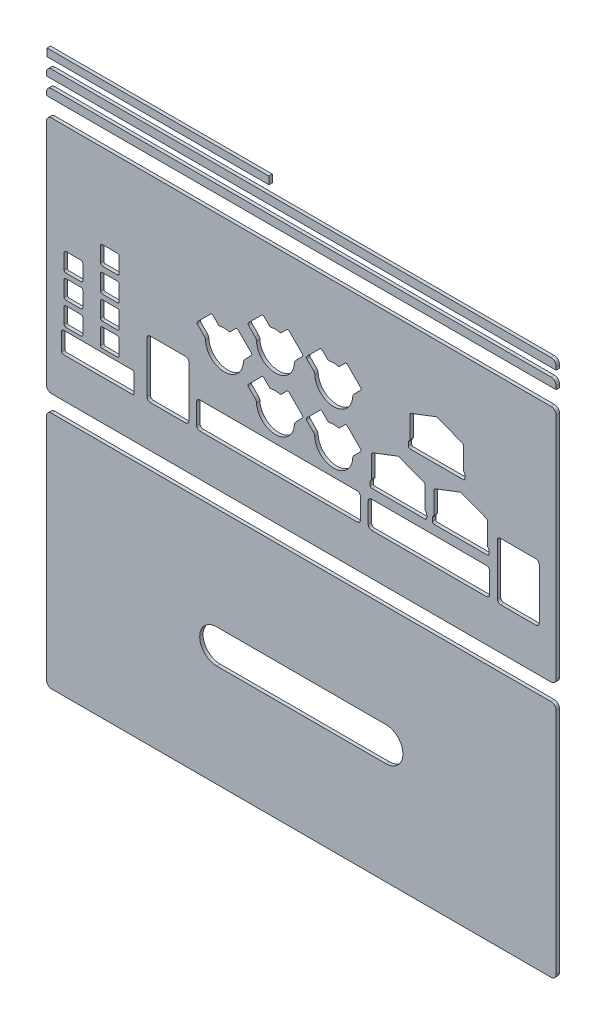
from build123d import *

# Parameters (mm, degrees)
SKETCH_1_W             = 301
SKETCH_1_H             = 141
SKETCH_1_W_2           = 11
SKETCH_1_H_2           = 11
SKETCH_1_W_3           = 42.882009629
SKETCH_1_H_3           = 12.463384351
EXTRUDE_1_DEPTH        = 2
FILLET_1_R             = 3
FILLET_2_R             = 1
SKETCH_2_W             = 301
SKETCH_2_H             = 5
EXTRUDE_2_DEPTH        = 2
FILLET_3_R             = 3
PATTERN_LINEAR_1_COUNT = 2
PATTERN_LINEAR_1_PITCH = 10
SKETCH_3_W             = 131
SKETCH_3_H             = 4.5
EXTRUDE_3_DEPTH        = 2
SKETCH_4_W             = 301
SKETCH_4_H             = 141
EXTRUDE_4_DEPTH        = 2
FILLET_4_R             = 3
CUT_EXTRUDE_1_DEPTH    = 2


with BuildPart() as part:
    # 草图1 → 凸台-拉伸1 (new body)
    with BuildSketch(Plane.XY):
        with Locations((145.5, 65.5)):
            Rectangle(SKETCH_1_W, SKETCH_1_H)
        with BuildLine():
            Line((107.479342602, 83.3954791), (103.152633216, 79.068769714))
            ThreePointArc((103.152633216, 79.068769714), (100.048889892, 79.525854826), (96.945146567, 79.068769714))
            Line((96.945146567, 79.068769714), (92.630133634, 83.383782646))
            Line((92.630133634, 83.383782646), (83.501399592, 74.255048604))
            Line((83.501399592, 74.255048604), (88.051647854, 69.704800341))
            ThreePointArc((88.051647854, 69.704800341), (88.68925935, 68.747618373), (88.908844178, 67.618668312))
            ThreePointArc((88.908844178, 67.618668312), (100.084096134, 57.15569059), (111.270007089, 67.607272058))
            ThreePointArc((111.270007089, 67.607272058), (111.532715847, 68.742609725), (112.190132556, 69.704800341))
            Line((112.190132556, 69.704800341), (116.680076959, 74.194744744))
            Line((116.680076959, 74.194744744), (107.479342602, 83.3954791))
        make_face(mode=Mode.SUBTRACT)
        with BuildLine():
            Line((137.61695402, 97.935247029), (133.290244634, 93.608537643))
            ThreePointArc((133.290244634, 93.608537643), (130.186501309, 94.065622755), (127.082757985, 93.608537643))
            Line((127.082757985, 93.608537643), (122.767745052, 97.923550576))
            Line((122.767745052, 97.923550576), (113.639011009, 88.794816533))
            Line((113.639011009, 88.794816533), (118.189259272, 84.24456827))
            ThreePointArc((118.189259272, 84.24456827), (118.826870768, 83.287386303), (119.046455596, 82.158436241))
            ThreePointArc((119.046455596, 82.158436241), (130.221707552, 71.695458519), (141.407618507, 82.147039988))
            ThreePointArc((141.407618507, 82.147039988), (141.670327265, 83.282377655), (142.327743974, 84.24456827))
            Line((142.327743974, 84.24456827), (146.817688376, 88.734512673))
            Line((146.817688376, 88.734512673), (137.61695402, 97.935247029))
        make_face(mode=Mode.SUBTRACT)
        with BuildLine():
            Line((172.054755422, 97.935247029), (167.728046035, 93.608537643))
            ThreePointArc((167.728046035, 93.608537643), (164.624302711, 94.065622755), (161.520559387, 93.608537643))
            Line((161.520559387, 93.608537643), (157.205546454, 97.923550576))
            Line((157.205546454, 97.923550576), (148.076812411, 88.794816533))
            Line((148.076812411, 88.794816533), (152.627060674, 84.24456827))
            ThreePointArc((152.627060674, 84.24456827), (153.26467217, 83.287386303), (153.484256998, 82.158436241))
            ThreePointArc((153.484256998, 82.158436241), (164.659508954, 71.695458519), (175.845419909, 82.147039988))
            ThreePointArc((175.845419909, 82.147039988), (176.108128666, 83.282377655), (176.765545376, 84.24456827))
            Line((176.765545376, 84.24456827), (181.255489778, 88.734512673))
            Line((181.255489778, 88.734512673), (172.054755422, 97.935247029))
        make_face(mode=Mode.SUBTRACT)
        with BuildLine():
            Line((172.008536395, 66.461273637), (167.681827008, 62.13456425))
            ThreePointArc((167.681827008, 62.13456425), (164.578083684, 62.591649363), (161.474340359, 62.13456425))
            Line((161.474340359, 62.13456425), (157.159327427, 66.449577183))
            Line((157.159327427, 66.449577183), (148.030593384, 57.32084314))
            Line((148.030593384, 57.32084314), (152.580841647, 52.770594878))
            ThreePointArc((152.580841647, 52.770594878), (153.218453142, 51.81341291), (153.43803797, 50.684462848))
            ThreePointArc((153.43803797, 50.684462848), (164.613289926, 40.221485126), (175.799200881, 50.673066595))
            ThreePointArc((175.799200881, 50.673066595), (176.061909639, 51.808404262), (176.719326348, 52.770594878))
            Line((176.719326348, 52.770594878), (181.209270751, 57.26053928))
            Line((181.209270751, 57.26053928), (172.008536395, 66.461273637))
        make_face(mode=Mode.SUBTRACT)
        with BuildLine():
            Line((137.61695402, 66.461273637), (133.290244634, 62.13456425))
            ThreePointArc((133.290244634, 62.13456425), (130.186501309, 62.591649363), (127.082757985, 62.13456425))
            Line((127.082757985, 62.13456425), (122.767745052, 66.449577183))
            Line((122.767745052, 66.449577183), (113.639011009, 57.32084314))
            Line((113.639011009, 57.32084314), (118.189259272, 52.770594878))
            ThreePointArc((118.189259272, 52.770594878), (118.826870768, 51.81341291), (119.046455596, 50.684462848))
            ThreePointArc((119.046455596, 50.684462848), (130.221707552, 40.221485126), (141.407618507, 50.673066595))
            ThreePointArc((141.407618507, 50.673066595), (141.670327265, 51.808404262), (142.327743974, 52.770594878))
            Line((142.327743974, 52.770594878), (146.817688376, 57.26053928))
            Line((146.817688376, 57.26053928), (137.61695402, 66.461273637))
        make_face(mode=Mode.SUBTRACT)
        Polygon((241.240019748, 90.803703673), (225.444911387, 96.887575353), (209.649803026, 90.803703673), (209.649803026, 77.052080268), (208.690506582, 75.840282178), (208.690506582, 72.632530051), (242.199316192, 72.632530051), (242.199316192, 75.840282178), (241.240019748, 77.052080268), align=None, mode=Mode.SUBTRACT)
        Polygon((218.625141178, 59.339189893), (202.830032817, 65.423061573), (187.034924456, 59.339189893), (187.034924456, 45.587566488), (186.075628012, 44.375768398), (186.075628012, 41.16801627), (219.584437622, 41.16801627), (219.584437622, 44.375768398), (218.625141178, 45.587566488), align=None, mode=Mode.SUBTRACT)
        Polygon((255.450830995, 59.339189893), (239.655722634, 65.423061573), (223.860614273, 59.339189893), (223.860614273, 45.587566488), (222.901317829, 44.375768398), (222.901317829, 41.16801627), (256.410127439, 41.16801627), (256.410127439, 44.375768398), (255.450830995, 45.587566488), align=None, mode=Mode.SUBTRACT)
        with Locations((32.437030163, 66.470141032)):
            Rectangle(SKETCH_1_W_2, SKETCH_1_H_2, mode=Mode.SUBTRACT)
        with BuildLine():
            Line((56.30337663, 53.628236384), (77.135061372, 53.628236384))
            ThreePointArc((77.135061372, 53.628236384), (78.549274934, 53.042449946), (79.135061372, 51.628236384))
            Line((79.135061372, 51.628236384), (79.135061372, 21.643814676))
            ThreePointArc((79.135061372, 21.643814676), (78.549274934, 20.229601113), (77.135061372, 19.643814676))
            Line((77.135061372, 19.643814676), (56.30337663, 19.643814676))
            ThreePointArc((56.30337663, 19.643814676), (54.889163068, 20.229601113), (54.30337663, 21.643814676))
            Line((54.30337663, 21.643814676), (54.30337663, 51.628236384))
            ThreePointArc((54.30337663, 51.628236384), (54.889163068, 53.042449946), (56.30337663, 53.628236384))
        make_face(mode=Mode.SUBTRACT)
        with BuildLine():
            Line((85.64105795, 35.56703416), (178.463172629, 35.56703416))
            ThreePointArc((178.463172629, 35.56703416), (179.877386192, 34.981247723), (180.463172629, 33.56703416))
            Line((180.463172629, 33.56703416), (180.463172629, 21.643814676))
            ThreePointArc((180.463172629, 21.643814676), (179.877386192, 20.229601113), (178.463172629, 19.643814676))
            Line((178.463172629, 19.643814676), (85.64105795, 19.643814676))
            ThreePointArc((85.64105795, 19.643814676), (84.226844388, 20.229601113), (83.64105795, 21.643814676))
            Line((83.64105795, 21.643814676), (83.64105795, 33.56703416))
            ThreePointArc((83.64105795, 33.56703416), (84.226844388, 34.981247723), (85.64105795, 35.56703416))
        make_face(mode=Mode.SUBTRACT)
        with BuildLine():
            Line((186.992635112, 35.56703416), (254.771670514, 35.56703416))
            ThreePointArc((254.771670514, 35.56703416), (256.185884076, 34.981247723), (256.771670514, 33.56703416))
            Line((256.771670514, 33.56703416), (256.771670514, 21.643814676))
            ThreePointArc((256.771670514, 21.643814676), (256.185884076, 20.229601113), (254.771670514, 19.643814676))
            Line((254.771670514, 19.643814676), (186.992635112, 19.643814676))
            ThreePointArc((186.992635112, 19.643814676), (185.578421549, 20.229601113), (184.992635112, 21.643814676))
            Line((184.992635112, 21.643814676), (184.992635112, 33.56703416))
            ThreePointArc((184.992635112, 33.56703416), (185.578421549, 34.981247723), (186.992635112, 35.56703416))
        make_face(mode=Mode.SUBTRACT)
        with BuildLine():
            Line((284.023192698, 53.585306134), (263.2536236, 53.585306134))
            ThreePointArc((263.2536236, 53.585306134), (261.839410038, 52.999519696), (261.2536236, 51.585306134))
            Line((261.2536236, 51.585306134), (261.2536236, 21.643814676))
            ThreePointArc((261.2536236, 21.643814676), (261.839410038, 20.229601113), (263.2536236, 19.643814676))
            Line((263.2536236, 19.643814676), (284.023192698, 19.643814676))
            ThreePointArc((284.023192698, 19.643814676), (285.43740626, 20.229601113), (286.023192698, 21.643814676))
            Line((286.023192698, 21.643814676), (286.023192698, 51.585306134))
            ThreePointArc((286.023192698, 51.585306134), (285.43740626, 52.999519696), (284.023192698, 53.585306134))
        make_face(mode=Mode.SUBTRACT)
        with Locations((10.937030163, 66.470141032)):
            Rectangle(SKETCH_1_W_2, SKETCH_1_H_2, mode=Mode.SUBTRACT)
        with Locations((10.937030163, 52.570141032)):
            Rectangle(SKETCH_1_W_2, SKETCH_1_H_2, mode=Mode.SUBTRACT)
        with Locations((10.937030163, 38.670141032)):
            Rectangle(SKETCH_1_W_2, SKETCH_1_H_2, mode=Mode.SUBTRACT)
        with Locations((32.437030163, 52.570141032)):
            Rectangle(SKETCH_1_W_2, SKETCH_1_H_2, mode=Mode.SUBTRACT)
        with Locations((32.437030163, 38.670141032)):
            Rectangle(SKETCH_1_W_2, SKETCH_1_H_2, mode=Mode.SUBTRACT)
        with Locations((32.437030163, 80.777013442)):
            Rectangle(SKETCH_1_W_2, SKETCH_1_H_2, mode=Mode.SUBTRACT)
        with Locations((25.396549479, 24.755667101)):
            Rectangle(SKETCH_1_W_3, SKETCH_1_H_3, mode=Mode.SUBTRACT)
    extrude(amount=-EXTRUDE_1_DEPTH)

    # 圆角1
    fillet_1_edges = [part.edges().sort_by_distance(p)[0] for p in [
        (-5, 136, -1),
        (296, 136, -1),
        (296, -5, -1),
        (-5, -5, -1),
    ]]
    fillet(fillet_1_edges, radius=FILLET_1_R)

    # 圆角2
    fillet_2_edges = [part.edges().sort_by_distance(p)[0] for p in [
        (161.474340359, 62.13456425, -1),
        (167.681827008, 62.13456425, -1),
        (172.008536395, 66.461273637, -1),
        (181.209270751, 57.26053928, -1),
        (175.799200881, 50.673066595, -1),
        (153.43803797, 50.684462848, -1),
        (148.030593384, 57.32084314, -1),
        (157.159327427, 66.449577183, -1),
        (127.082757985, 62.13456425, -1),
        (133.290244634, 62.13456425, -1),
        (137.61695402, 66.461273637, -1),
        (146.817688376, 57.26053928, -1),
        (141.407618507, 50.673066595, -1),
        (119.046455596, 50.684462848, -1),
        (113.639011009, 57.32084314, -1),
        (122.767745052, 66.449577183, -1),
        (241.240019748, 90.803703673, -1),
        (241.240019748, 77.052080268, -1),
        (242.199316192, 75.840282178, -1),
        (242.199316192, 72.632530051, -1),
        (208.690506582, 72.632530051, -1),
        (208.690506582, 75.840282178, -1),
        (209.649803026, 77.052080268, -1),
        (209.649803026, 90.803703673, -1),
        (225.444911387, 96.887575353, -1),
        (218.625141178, 59.339189893, -1),
        (218.625141178, 45.587566488, -1),
        (219.584437622, 44.375768398, -1),
        (219.584437622, 41.16801627, -1),
        (186.075628012, 41.16801627, -1),
        (186.075628012, 44.375768398, -1),
        (187.034924456, 45.587566488, -1),
        (187.034924456, 59.339189893, -1),
        (202.830032817, 65.423061573, -1),
        (96.945146567, 79.068769714, -1),
        (103.152633216, 79.068769714, -1),
        (107.479342602, 83.3954791, -1),
        (116.680076959, 74.194744744, -1),
        (255.450830995, 59.339189893, -1),
        (255.450830995, 45.587566488, -1),
        (256.410127439, 44.375768398, -1),
        (256.410127439, 41.16801627, -1),
        (222.901317829, 41.16801627, -1),
        (222.901317829, 44.375768398, -1),
        (223.860614273, 45.587566488, -1),
        (223.860614273, 59.339189893, -1),
        (239.655722634, 65.423061573, -1),
        (111.270007089, 67.607272058, -1),
        (88.908844178, 67.618668312, -1),
        (83.501399592, 74.255048604, -1),
        (92.630133634, 83.383782646, -1),
        (26.937030163, 60.970141032, -1),
        (26.937030163, 71.970141032, -1),
        (37.937030163, 71.970141032, -1),
        (37.937030163, 60.970141032, -1),
        (26.937030163, 75.277013442, -1),
        (26.937030163, 86.277013442, -1),
        (37.937030163, 86.277013442, -1),
        (37.937030163, 75.277013442, -1),
        (5.437030163, 71.970141032, -1),
        (16.437030163, 71.970141032, -1),
        (16.437030163, 60.970141032, -1),
        (5.437030163, 60.970141032, -1),
        (5.437030163, 58.070141032, -1),
        (16.437030163, 58.070141032, -1),
        (16.437030163, 47.070141032, -1),
        (5.437030163, 47.070141032, -1),
        (5.437030163, 44.170141032, -1),
        (16.437030163, 44.170141032, -1),
        (16.437030163, 33.170141032, -1),
        (5.437030163, 33.170141032, -1),
        (26.937030163, 58.070141032, -1),
        (37.937030163, 58.070141032, -1),
        (37.937030163, 47.070141032, -1),
        (26.937030163, 47.070141032, -1),
        (26.937030163, 44.170141032, -1),
        (37.937030163, 44.170141032, -1),
        (37.937030163, 33.170141032, -1),
        (26.937030163, 33.170141032, -1),
        (3.955544665, 18.523974925, -1),
        (3.955544665, 30.987359276, -1),
        (46.837554294, 30.987359276, -1),
        (46.837554294, 18.523974925, -1),
        (127.082757985, 93.608537643, -1),
        (133.290244634, 93.608537643, -1),
        (137.61695402, 97.935247029, -1),
        (146.817688376, 88.734512673, -1),
        (141.407618507, 82.147039988, -1),
        (119.046455596, 82.158436241, -1),
        (113.639011009, 88.794816533, -1),
        (122.767745052, 97.923550576, -1),
        (161.520559387, 93.608537643, -1),
        (167.728046035, 93.608537643, -1),
        (172.054755422, 97.935247029, -1),
        (181.255489778, 88.734512673, -1),
        (175.845419909, 82.147039988, -1),
        (153.484256998, 82.158436241, -1),
        (148.076812411, 88.794816533, -1),
        (157.205546454, 97.923550576, -1),
    ]]
    fillet(fillet_2_edges, radius=FILLET_2_R)


with BuildPart() as body_2:
    # 草图2 → 凸台-拉伸2 (new body)
    with BuildSketch(Plane.XY):
        with Locations((145.5, 148.5)):
            Rectangle(SKETCH_2_W, SKETCH_2_H)
    extrude(amount=-EXTRUDE_2_DEPTH)

    # 圆角3
    fillet_3_edges = [body_2.edges().sort_by_distance(p)[0] for p in [
        (-5, 151, -1),
        (296, 151, -1),
    ]]
    fillet(fillet_3_edges, radius=FILLET_3_R)


with BuildPart() as pattern_linear_1_1:
    # 阵列(线性)1: pattern copy
    add(body_2.part.moved(Location(Vector(0, 1, 0) * (1 * PATTERN_LINEAR_1_PITCH))))


with BuildPart() as body_4:
    # 草图3 → 凸台-拉伸3 (new body)
    with BuildSketch(Plane.XY):
        with Locations((60.862300303, 168.25)):
            Rectangle(SKETCH_3_W, SKETCH_3_H)
    extrude(amount=-EXTRUDE_3_DEPTH)


with BuildPart() as body_5:
    # 草图4 → 凸台-拉伸4 (new body)
    with BuildSketch(Plane.XY):
        with Locations((145.5, -85.5)):
            Rectangle(SKETCH_4_W, SKETCH_4_H)
    extrude(amount=-EXTRUDE_4_DEPTH)

    # 圆角4
    fillet_4_edges = [body_5.edges().sort_by_distance(p)[0] for p in [
        (-5, -15, -1),
        (296, -15, -1),
        (296, -156, -1),
        (-5, -156, -1),
    ]]
    fillet(fillet_4_edges, radius=FILLET_4_R)

    # 草图6 → 切除-拉伸1 (cut)
    with BuildSketch(Plane.XY):
        with BuildLine():
            Line((95.5, -75.5), (195.5, -75.5))
            ThreePointArc((195.5, -75.5), (205.5, -85.5), (195.5, -95.5))
            Line((195.5, -95.5), (95.5, -95.5))
            ThreePointArc((95.5, -95.5), (85.5, -85.5), (95.5, -75.5))
        make_face()
    extrude(amount=-CUT_EXTRUDE_1_DEPTH, mode=Mode.SUBTRACT)


solid = Compound([part.part, body_2.part, pattern_linear_1_1.part, body_4.part, body_5.part])
